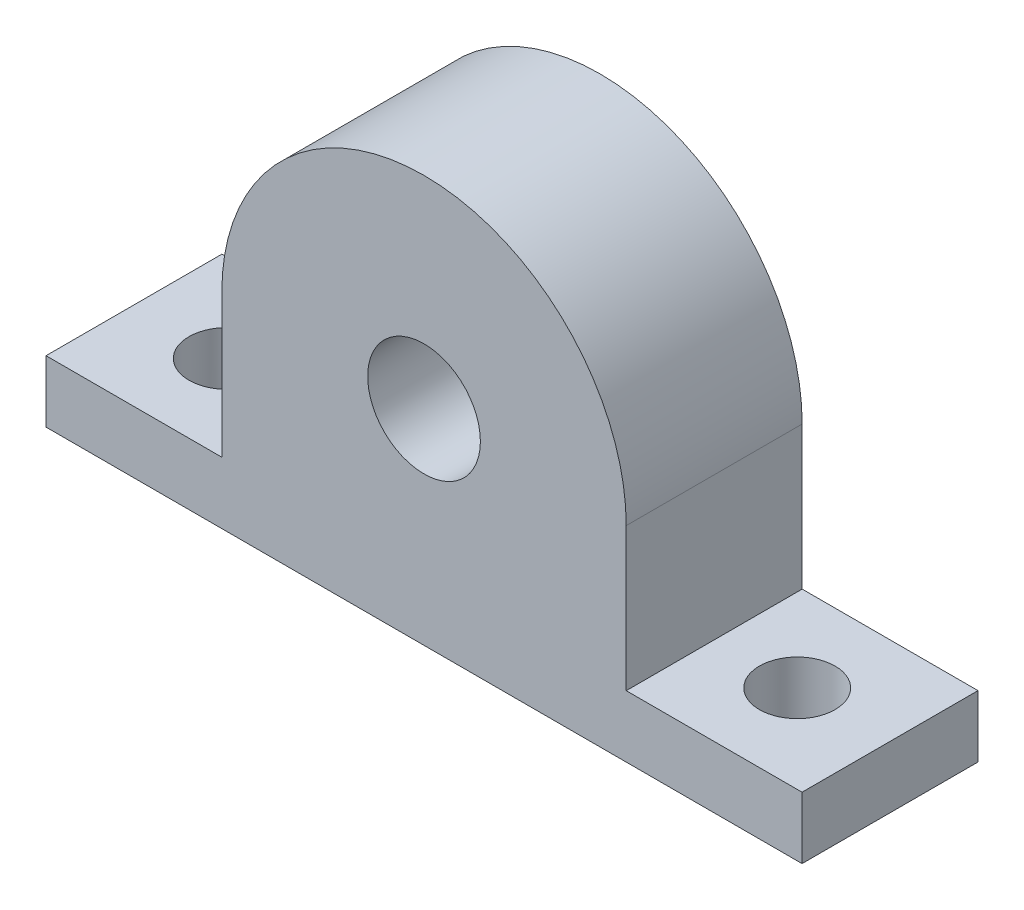
from build123d import *

# Parameters (mm, degrees)
SKETCH1_R           = 4.1
BOSS_EXTRUDE1_DEPTH = 12.8
SKETCH2_R           = 2.75
CUT_EXTRUDE1_DEPTH  = 30.609218923


with BuildPart() as part:
    # Sketch1 → Boss-Extrude1 (new body)
    with BuildSketch(Plane.XY):
        with BuildLine():
            Line((-27.5, 4.5), (-27.5, 0))
            Line((-27.5, 0), (27.5, 0))
            Line((27.5, 0), (27.5, 4.5))
            Line((27.5, 4.5), (14.709218923, 4.5))
            Line((14.709218923, 4.5), (14.709218923, 14.9))
            ThreePointArc((14.709218923, 14.9), (0, 29.609218923), (-14.709218923, 14.9))
            Line((-14.709218923, 14.9), (-14.709218923, 4.5))
            Line((-14.709218923, 4.5), (-27.5, 4.5))
        make_face()
        with Locations((0, 14.9)):
            Circle(SKETCH1_R, mode=Mode.SUBTRACT)
    extrude(amount=BOSS_EXTRUDE1_DEPTH)

    # Sketch2 → Cut-Extrude1 (cut, through all)
    with BuildSketch(Plane.XZ):
        with Locations((-20.75, 6.4)):
            Circle(SKETCH2_R)
        with Locations((20.75, 6.4)):
            Circle(SKETCH2_R)
    extrude(amount=-CUT_EXTRUDE1_DEPTH, mode=Mode.SUBTRACT)


solid = part.part
